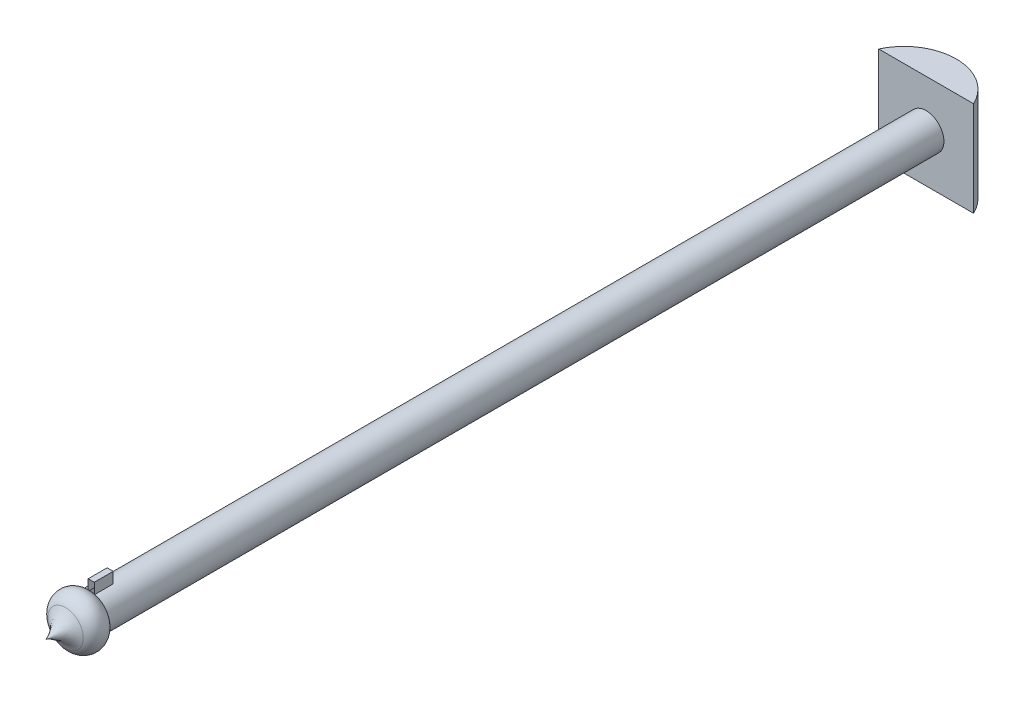
from build123d import *

# Parameters (mm, degrees)
SKETCH1_R           = 2.38125
BOSS_EXTRUDE1_DEPTH = 114.3
BOSS_EXTRUDE2_DEPTH = 6.35
BOSS_EXTRUDE3_DEPTH = 2.54


with BuildPart() as part:
    # Sketch1 → Boss-Extrude1 (new body)
    with BuildSketch(Plane.XY):
        Circle(SKETCH1_R)
    extrude(amount=BOSS_EXTRUDE1_DEPTH)

    # Sketch2 → Boss-Extrude2 (add, symmetric)
    with BuildSketch(Plane(origin=(0, 0, 0), x_dir=(1, 0, 0), z_dir=(0, 1, 0))):
        with BuildLine():
            Line((-6.35, -2.563701192), (0, -2.563701192))
            Line((0, -2.563701192), (6.35, -2.563701192))
            ThreePointArc((6.35, -2.563701192), (0, 1.474189404), (-6.35, -2.563701192))
        make_face()
    extrude(amount=BOSS_EXTRUDE2_DEPTH, both=True)

    # Sketch3 → Boss-Extrude3 (add)
    with BuildSketch(Plane.XY.offset(114.3)):
        Polygon((0, 0), (-0.393640411, 0), (-0.393640411, 3.800666036), (0.420788025, 3.800666036), (0.420788025, 0), align=None)
    extrude(amount=-BOSS_EXTRUDE3_DEPTH)

    # Sketch6 → Revolve1 (revolve)
    with BuildSketch(Plane(origin=(0, 0, 0), x_dir=(1, 0, 0), z_dir=(0, 1, 0))):
        with BuildLine():
            Line((-2.38125, -114.3), (-2.1348e-05, -114.3))
            Line((-2.1348e-05, -114.3), (-2.1348e-05, -120.337767792))
            ThreePointArc((-2.1348e-05, -120.337767792), (-0.926983302, -118.795624498), (-2.370821649, -117.721941476))
            ThreePointArc((-2.370821649, -117.721941476), (-3.452807259, -116.014252194), (-2.38125, -114.3))
        make_face()
    revolve(axis=Axis((-2.1348e-05, 0, 114.3), (0, 0, 1)))


solid = part.part
